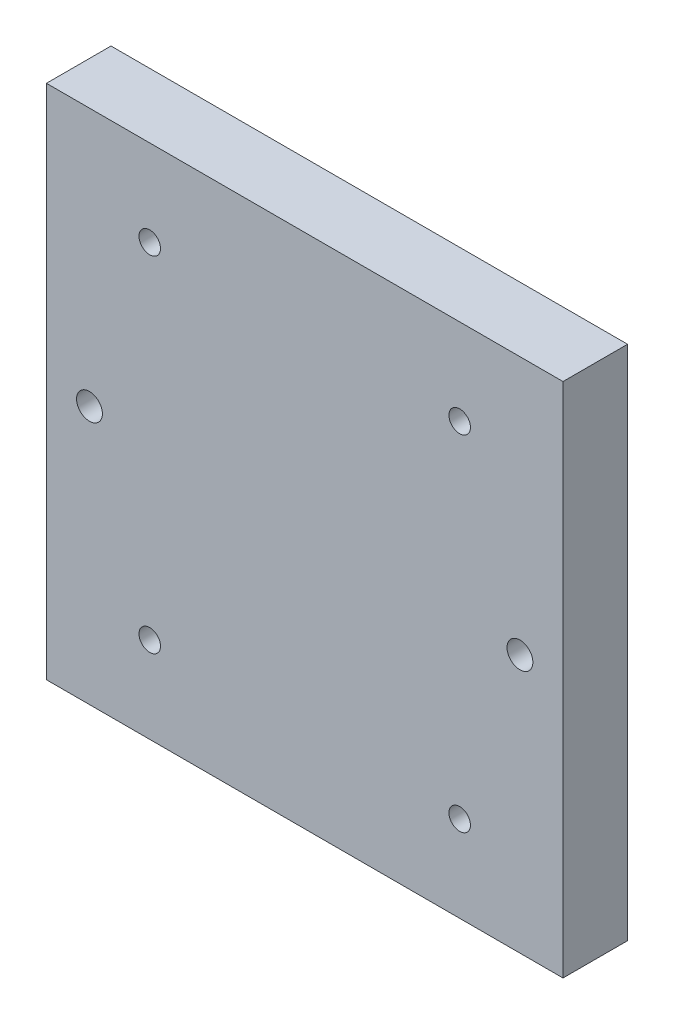
from build123d import *

# Parameters (mm, degrees)
SKETCH1_W           = 120
SKETCH1_H           = 120
BOSS_EXTRUDE1_DEPTH = 15
CUT_EXTRUDE4_REACH  = 17
SKETCH7_R           = 2.5
SKETCH7_R_2         = 3


with BuildPart() as part:
    # Sketch1 → Boss-Extrude1 (new body)
    with BuildSketch(Plane.XY):
        Rectangle(SKETCH1_W, SKETCH1_H)
    extrude(amount=-BOSS_EXTRUDE1_DEPTH)

    # Sketch7 → Cut-Extrude4 (cut, up to next)
    with BuildSketch(Plane(origin=(0, 0, -15), x_dir=(-1, 0, 0), z_dir=(0, 0, -1)), mode=Mode.PRIVATE) as cut_extrude4_sk1:
        with Locations((-36, -40)):
            Circle(SKETCH7_R)
    cut_extrude4_tool1 = extrude(cut_extrude4_sk1.sketch, amount=-CUT_EXTRUDE4_REACH, mode=Mode.PRIVATE) & part.part
    add(cut_extrude4_tool1.solids().sort_by_distance((36, -40, -15))[0], mode=Mode.SUBTRACT)
    # Sketch7 → Cut-Extrude4 (cut, up to next)
    with BuildSketch(Plane(origin=(0, 0, -15), x_dir=(-1, 0, 0), z_dir=(0, 0, -1)), mode=Mode.PRIVATE) as cut_extrude4_sk2:
        with Locations((-36, 40)):
            Circle(SKETCH7_R)
    cut_extrude4_tool2 = extrude(cut_extrude4_sk2.sketch, amount=-CUT_EXTRUDE4_REACH, mode=Mode.PRIVATE) & part.part
    add(cut_extrude4_tool2.solids().sort_by_distance((36, 40, -15))[0], mode=Mode.SUBTRACT)
    # Sketch7 → Cut-Extrude4 (cut, up to next)
    with BuildSketch(Plane(origin=(0, 0, -15), x_dir=(-1, 0, 0), z_dir=(0, 0, -1)), mode=Mode.PRIVATE) as cut_extrude4_sk3:
        with Locations((36, -40)):
            Circle(SKETCH7_R)
    cut_extrude4_tool3 = extrude(cut_extrude4_sk3.sketch, amount=-CUT_EXTRUDE4_REACH, mode=Mode.PRIVATE) & part.part
    add(cut_extrude4_tool3.solids().sort_by_distance((-36, -40, -15))[0], mode=Mode.SUBTRACT)
    # Sketch7 → Cut-Extrude4 (cut, up to next)
    with BuildSketch(Plane(origin=(0, 0, -15), x_dir=(-1, 0, 0), z_dir=(0, 0, -1)), mode=Mode.PRIVATE) as cut_extrude4_sk4:
        with Locations((36, 40)):
            Circle(SKETCH7_R)
    cut_extrude4_tool4 = extrude(cut_extrude4_sk4.sketch, amount=-CUT_EXTRUDE4_REACH, mode=Mode.PRIVATE) & part.part
    add(cut_extrude4_tool4.solids().sort_by_distance((-36, 40, -15))[0], mode=Mode.SUBTRACT)
    # Sketch7 → Cut-Extrude4 (cut, up to next)
    with BuildSketch(Plane(origin=(0, 0, -15), x_dir=(-1, 0, 0), z_dir=(0, 0, -1)), mode=Mode.PRIVATE) as cut_extrude4_sk5:
        with Locations((50, 0)):
            Circle(SKETCH7_R_2)
    cut_extrude4_tool5 = extrude(cut_extrude4_sk5.sketch, amount=-CUT_EXTRUDE4_REACH, mode=Mode.PRIVATE) & part.part
    add(cut_extrude4_tool5.solids().sort_by_distance((-50, 0, -15))[0], mode=Mode.SUBTRACT)
    # Sketch7 → Cut-Extrude4 (cut, up to next)
    with BuildSketch(Plane(origin=(0, 0, -15), x_dir=(-1, 0, 0), z_dir=(0, 0, -1)), mode=Mode.PRIVATE) as cut_extrude4_sk6:
        with Locations((-50, 0)):
            Circle(SKETCH7_R_2)
    cut_extrude4_tool6 = extrude(cut_extrude4_sk6.sketch, amount=-CUT_EXTRUDE4_REACH, mode=Mode.PRIVATE) & part.part
    add(cut_extrude4_tool6.solids().sort_by_distance((50, 0, -15))[0], mode=Mode.SUBTRACT)


solid = part.part
